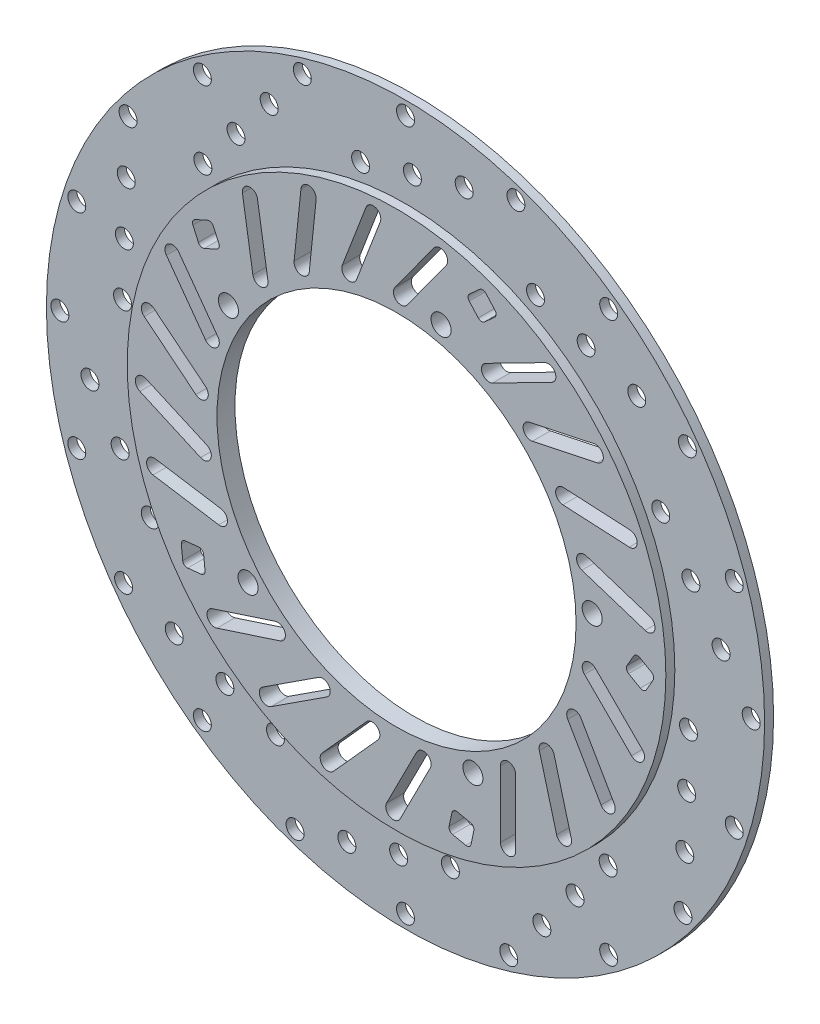
from build123d import *

# Parameters (mm, degrees)
SKETCH1_R           = 300
SKETCH1_R_2         = 200
BOSS_EXTRUDE1_DEPTH = 20
SKETCH2_R           = 400
SKETCH2_R_2         = 300
BOSS_EXTRUDE3_DEPTH = 10
SKETCH3_R           = 10
CUT_EXTRUDE3_DEPTH  = 44
CIRPATTERN1_COUNT   = 10
SKETCH4_R           = 11.175
CUT_EXTRUDE4_DEPTH  = 44
CIRPATTERN2_COUNT   = 5


with BuildPart() as part:
    # Sketch1 → Boss-Extrude1 (new body)
    with BuildSketch(Plane.XY):
        Circle(SKETCH1_R)
        Circle(SKETCH1_R_2, mode=Mode.SUBTRACT)
    extrude(amount=BOSS_EXTRUDE1_DEPTH)

    # Sketch2 → Boss-Extrude3 (add)
    with BuildSketch(Plane.XY):
        Circle(SKETCH2_R)
        Circle(SKETCH2_R_2, mode=Mode.SUBTRACT)
    extrude(amount=BOSS_EXTRUDE3_DEPTH)

    # Sketch3 → Cut-Extrude3 (cut)
    with BuildSketch(Plane.XY):
        with Locations((0, 385)):
            Circle(SKETCH3_R)
        with Locations((-50, 315.205680543)):
            Circle(SKETCH3_R)
        with Locations((123.006261275, 364.89303869)):
            Circle(SKETCH3_R)
        with Locations((7.668753758, 331.768133259)):
            Circle(SKETCH3_R)
        with Locations((65.337507517, 348.330585974)):
            Circle(SKETCH3_R)
    cut_extrude3 = extrude(amount=CUT_EXTRUDE3_DEPTH, mode=Mode.SUBTRACT)

    # CirPattern1: Cut-Extrude3 ×10 about axis
    cirpattern1_axis = Axis((0, 0, 0), (0, 0, 1))
    for i in range(1, CIRPATTERN1_COUNT):
        add(cut_extrude3.rotate(cirpattern1_axis, i * 360 / CIRPATTERN1_COUNT), mode=Mode.SUBTRACT)

    # Sketch4 → Cut-Extrude4 (cut)
    with BuildSketch(Plane.XY.offset(20)):
        with Locations((-187.278288879, 113.023769821)):
            Circle(SKETCH4_R)
        with BuildLine():
            Line((-200.387781681, 160.829535147), (-214.087006251, 154.719605019))
            ThreePointArc((-214.087006251, 154.719605019), (-217.912463482, 154.61695067), (-220.690057817, 157.249369833))
            Line((-220.690057817, 157.249369833), (-226.799987946, 170.948594403))
            ThreePointArc((-226.799987946, 170.948594403), (-226.902642295, 174.774051634), (-224.270223132, 177.551645969))
            Line((-224.270223132, 177.551645969), (-210.570998562, 183.661576098))
            ThreePointArc((-210.570998562, 183.661576098), (-206.745541331, 183.764230447), (-203.967946996, 181.131811284))
            Line((-203.967946996, 181.131811284), (-197.858016867, 167.432586714))
            ThreePointArc((-197.858016867, 167.432586714), (-197.755362518, 163.607129483), (-200.387781681, 160.829535147))
        make_face()
        with BuildLine():
            Line((55.343943642, 273.063335101), (11.886647276, 213.167897942))
            ThreePointArc((11.886647276, 213.167897942), (0.015049506, 211.279733121), (-1.873115315, 223.151330891))
            Line((-1.873115315, 223.151330891), (41.584181052, 283.04676805))
            ThreePointArc((41.584181052, 283.04676805), (53.455778822, 284.934932871), (55.343943642, 273.063335101))
        make_face()
        with BuildLine():
            Line((-18.094022594, 278.406764135), (-44.568467644, 209.304638558))
            ThreePointArc((-44.568467644, 209.304638558), (-55.546857513, 204.408215795), (-60.443280276, 215.386605664))
            Line((-60.443280276, 215.386605664), (-33.968835227, 284.488731241))
            ThreePointArc((-33.968835227, 284.488731241), (-22.990445358, 289.385154005), (-18.094022594, 278.406764135))
        make_face()
        with BuildLine():
            Line((-89.534456569, 264.237206042), (-97.221860622, 190.637587708))
            ThreePointArc((-97.221860622, 190.637587708), (-106.558883464, 183.066590122), (-114.12988105, 192.403612963))
            Line((-114.12988105, 192.403612963), (-106.442476997, 266.003231298))
            ThreePointArc((-106.442476997, 266.003231298), (-97.105454155, 273.574228884), (-89.534456569, 264.237206042))
        make_face()
        with BuildLine():
            Line((-154.873265291, 232.06031903), (-143.249744466, 158.978900299))
            ThreePointArc((-143.249744466, 158.978900299), (-150.309097604, 149.249278864), (-160.038719039, 156.308632002))
            Line((-160.038719039, 156.308632002), (-171.662239864, 229.390050732))
            ThreePointArc((-171.662239864, 229.390050732), (-164.602886726, 239.119672167), (-154.873265291, 232.06031903))
        make_face()
    cut_extrude4 = extrude(amount=-CUT_EXTRUDE4_DEPTH, mode=Mode.SUBTRACT)

    # CirPattern2: Cut-Extrude4 ×5 about axis
    cirpattern2_axis = Axis((0, 0, 0), (0, 0, 1))
    for i in range(1, CIRPATTERN2_COUNT):
        add(cut_extrude4.rotate(cirpattern2_axis, i * 360 / CIRPATTERN2_COUNT), mode=Mode.SUBTRACT)


solid = part.part
